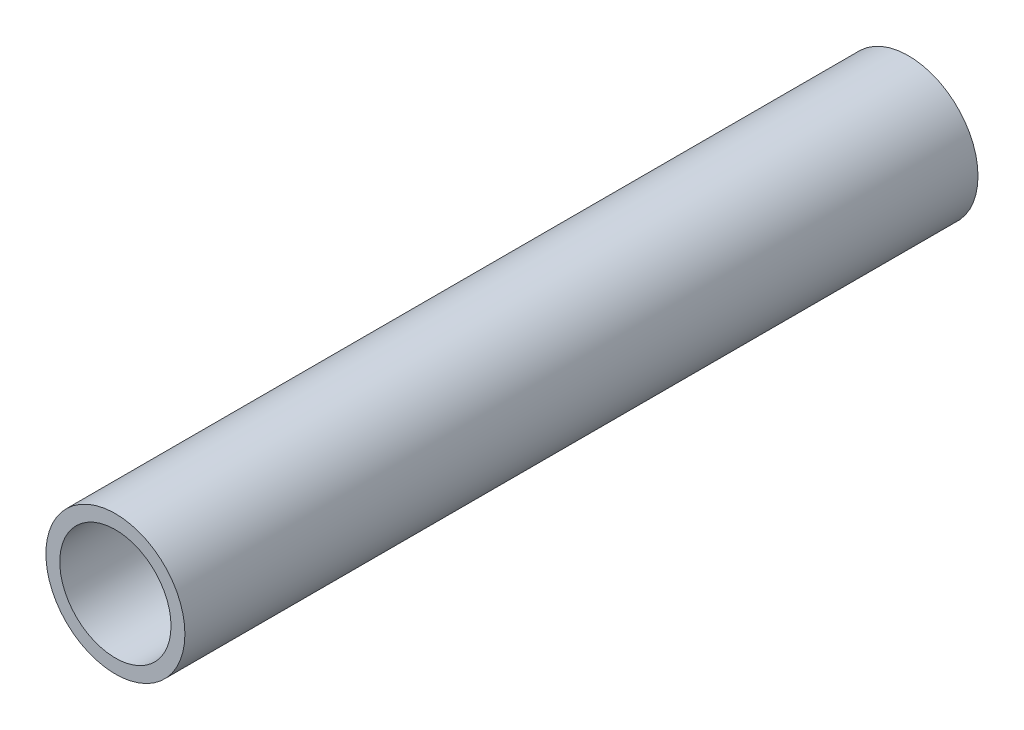
from build123d import *

# Parameters (mm, degrees)
SKETCH1_R           = 1.25
SKETCH1_R_2         = 1
BOSS_EXTRUDE1_DEPTH = 14.26


with BuildPart() as part:
    # Sketch1 → Boss-Extrude1 (new body)
    with BuildSketch(Plane.XY):
        Circle(SKETCH1_R)
        Circle(SKETCH1_R_2, mode=Mode.SUBTRACT)
    extrude(amount=BOSS_EXTRUDE1_DEPTH)


solid = part.part
